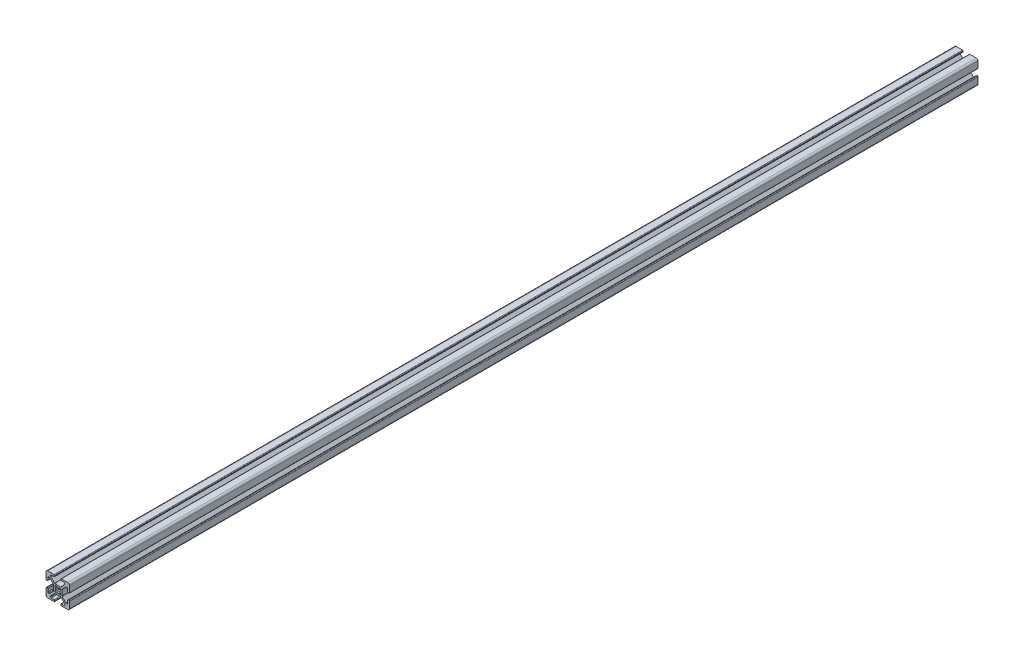
from build123d import *

# Parameters (mm, degrees)
BOSS_EXTRUDE1_DEPTH = 773.68


with BuildPart() as part:
    # Sketch1 → Boss-Extrude1 (new body)
    with BuildSketch(Plane(origin=(0, 0, -25), x_dir=(-1, 0, 0), z_dir=(0, 0, -1))):
        with BuildLine():
            Line((10, -8.5), (10, -3.138))
            ThreePointArc((10, -3.138), (9.851210245, -2.778789755), (9.492, -2.63))
            Line((9.492, -2.63), (9.008, -2.63))
            ThreePointArc((9.008, -2.63), (8.648789755, -2.778789755), (8.5, -3.138))
            Line((8.5, -3.138), (8.5, -5.487))
            ThreePointArc((8.5, -5.487), (8.351210245, -5.846210245), (7.992, -5.995))
            Line((7.992, -5.995), (7.26592049, -5.995))
            ThreePointArc((7.26592049, -5.995), (7.071517306, -5.956330803), (6.906710245, -5.846210245))
            Line((6.906710245, -5.846210245), (3.803789755, -2.743289755))
            ThreePointArc((3.803789755, -2.743289755), (3.693669197, -2.578482694), (3.655, -2.38407951))
            Line((3.655, -2.38407951), (3.655, 2.383759167))
            ThreePointArc((3.655, 2.383759167), (3.693669197, 2.57816235), (3.803789755, 2.742969412))
            Line((3.803789755, 2.742969412), (6.907030588, 5.846210245))
            ThreePointArc((6.907030588, 5.846210245), (7.07183765, 5.956330803), (7.266240833, 5.995))
            Line((7.266240833, 5.995), (7.992, 5.995))
            ThreePointArc((7.992, 5.995), (8.351210245, 5.846210245), (8.5, 5.487))
            Line((8.5, 5.487), (8.5, 3.138))
            ThreePointArc((8.5, 3.138), (8.648789755, 2.778789755), (9.008, 2.63))
            Line((9.008, 2.63), (9.492, 2.63))
            ThreePointArc((9.492, 2.63), (9.851210245, 2.778789755), (10, 3.138))
            Line((10, 3.138), (10, 8.5))
            ThreePointArc((10, 8.5), (9.560660172, 9.560660172), (8.5, 10))
            Line((8.5, 10), (3.138, 10))
            ThreePointArc((3.138, 10), (2.778789755, 9.851210245), (2.63, 9.492))
            Line((2.63, 9.492), (2.63, 9.008))
            ThreePointArc((2.63, 9.008), (2.778789755, 8.648789755), (3.138, 8.5))
            Line((3.138, 8.5), (5.487, 8.5))
            ThreePointArc((5.487, 8.5), (5.846210245, 8.351210245), (5.995, 7.992))
            Line((5.995, 7.992), (5.995, 7.26592049))
            ThreePointArc((5.995, 7.26592049), (5.956330803, 7.071517306), (5.846210245, 6.906710245))
            Line((5.846210245, 6.906710245), (2.743289755, 3.803789755))
            ThreePointArc((2.743289755, 3.803789755), (2.578482694, 3.693669197), (2.38407951, 3.655))
            Line((2.38407951, 3.655), (-2.383759167, 3.655))
            ThreePointArc((-2.383759167, 3.655), (-2.57816235, 3.693669197), (-2.742969412, 3.803789755))
            Line((-2.742969412, 3.803789755), (-5.846210245, 6.907030588))
            ThreePointArc((-5.846210245, 6.907030588), (-5.956330803, 7.07183765), (-5.995, 7.266240833))
            Line((-5.995, 7.266240833), (-5.995, 7.992))
            ThreePointArc((-5.995, 7.992), (-5.846210245, 8.351210245), (-5.487, 8.5))
            Line((-5.487, 8.5), (-3.138, 8.5))
            ThreePointArc((-3.138, 8.5), (-2.778789755, 8.648789755), (-2.63, 9.008))
            Line((-2.63, 9.008), (-2.63, 9.492))
            ThreePointArc((-2.63, 9.492), (-2.778789755, 9.851210245), (-3.138, 10))
            Line((-3.138, 10), (-8.5, 10))
            ThreePointArc((-8.5, 10), (-9.560660172, 9.560660172), (-10, 8.5))
            Line((-10, 8.5), (-10, 3.138))
            ThreePointArc((-10, 3.138), (-9.851210245, 2.778789755), (-9.492, 2.63))
            Line((-9.492, 2.63), (-9.008, 2.63))
            ThreePointArc((-9.008, 2.63), (-8.648789755, 2.778789755), (-8.5, 3.138))
            Line((-8.5, 3.138), (-8.5, 5.487))
            ThreePointArc((-8.5, 5.487), (-8.351210245, 5.846210245), (-7.992, 5.995))
            Line((-7.992, 5.995), (-7.26592049, 5.995))
            ThreePointArc((-7.26592049, 5.995), (-7.071517306, 5.956330803), (-6.906710245, 5.846210245))
            Line((-6.906710245, 5.846210245), (-3.803789755, 2.743289755))
            ThreePointArc((-3.803789755, 2.743289755), (-3.693669197, 2.578482694), (-3.655, 2.38407951))
            Line((-3.655, 2.38407951), (-3.655, -2.383759167))
            ThreePointArc((-3.655, -2.383759167), (-3.693669197, -2.57816235), (-3.803789755, -2.742969412))
            Line((-3.803789755, -2.742969412), (-6.907030588, -5.846210245))
            ThreePointArc((-6.907030588, -5.846210245), (-7.07183765, -5.956330803), (-7.266240833, -5.995))
            Line((-7.266240833, -5.995), (-7.992, -5.995))
            ThreePointArc((-7.992, -5.995), (-8.351210245, -5.846210245), (-8.5, -5.487))
            Line((-8.5, -5.487), (-8.5, -3.138))
            ThreePointArc((-8.5, -3.138), (-8.648789755, -2.778789755), (-9.008, -2.63))
            Line((-9.008, -2.63), (-9.492, -2.63))
            ThreePointArc((-9.492, -2.63), (-9.851210245, -2.778789755), (-10, -3.138))
            Line((-10, -3.138), (-10, -8.5))
            ThreePointArc((-10, -8.5), (-9.560660172, -9.560660172), (-8.5, -10))
            Line((-8.5, -10), (-3.138, -10))
            ThreePointArc((-3.138, -10), (-2.778789755, -9.851210245), (-2.63, -9.492))
            Line((-2.63, -9.492), (-2.63, -9.008))
            ThreePointArc((-2.63, -9.008), (-2.778789755, -8.648789755), (-3.138, -8.5))
            Line((-3.138, -8.5), (-5.487, -8.5))
            ThreePointArc((-5.487, -8.5), (-5.846210245, -8.351210245), (-5.995, -7.992))
            Line((-5.995, -7.992), (-5.995, -7.26592049))
            ThreePointArc((-5.995, -7.26592049), (-5.956330803, -7.071517306), (-5.846210245, -6.906710245))
            Line((-5.846210245, -6.906710245), (-2.743289755, -3.803789755))
            ThreePointArc((-2.743289755, -3.803789755), (-2.578482694, -3.693669197), (-2.38407951, -3.655))
            Line((-2.38407951, -3.655), (2.383759167, -3.655))
            ThreePointArc((2.383759167, -3.655), (2.57816235, -3.693669197), (2.742969412, -3.803789755))
            Line((2.742969412, -3.803789755), (5.846210245, -6.907030588))
            ThreePointArc((5.846210245, -6.907030588), (5.956330803, -7.07183765), (5.995, -7.266240833))
            Line((5.995, -7.266240833), (5.995, -7.992))
            ThreePointArc((5.995, -7.992), (5.846210245, -8.351210245), (5.487, -8.5))
            Line((5.487, -8.5), (3.138, -8.5))
            ThreePointArc((3.138, -8.5), (2.778789755, -8.648789755), (2.63, -9.008))
            Line((2.63, -9.008), (2.63, -9.492))
            ThreePointArc((2.63, -9.492), (2.778789755, -9.851210245), (3.138, -10))
            Line((3.138, -10), (8.5, -10))
            ThreePointArc((8.5, -10), (9.560660172, -9.560660172), (10, -8.5))
        make_face()
        with BuildLine():
            Line((2.304493037, -2.124493037), (2.124493037, -2.304493037))
            ThreePointArc((2.124493037, -2.304493037), (1.35638567, -2.506016078), (0.803729988, -1.935777391))
            ThreePointArc((0.803729988, -1.935777391), (0, -2.096), (-0.803729988, -1.935777391))
            ThreePointArc((-0.803729988, -1.935777391), (-1.35638567, -2.506016078), (-2.124493037, -2.304493037))
            Line((-2.124493037, -2.304493037), (-2.304493037, -2.124493037))
            ThreePointArc((-2.304493037, -2.124493037), (-2.506016078, -1.35638567), (-1.935777391, -0.803729988))
            ThreePointArc((-1.935777391, -0.803729988), (-2.096, 0), (-1.935777391, 0.803729988))
            ThreePointArc((-1.935777391, 0.803729988), (-2.506016078, 1.35638567), (-2.304493037, 2.124493037))
            Line((-2.304493037, 2.124493037), (-2.124493037, 2.304493037))
            ThreePointArc((-2.124493037, 2.304493037), (-1.35638567, 2.506016078), (-0.803729988, 1.935777391))
            ThreePointArc((-0.803729988, 1.935777391), (0, 2.096), (0.803729988, 1.935777391))
            ThreePointArc((0.803729988, 1.935777391), (1.35638567, 2.506016078), (2.124493037, 2.304493037))
            Line((2.124493037, 2.304493037), (2.304493037, 2.124493037))
            ThreePointArc((2.304493037, 2.124493037), (2.506016078, 1.35638567), (1.935777391, 0.803729988))
            ThreePointArc((1.935777391, 0.803729988), (2.096, 0), (1.935777391, -0.803729988))
            ThreePointArc((1.935777391, -0.803729988), (2.506016078, -1.35638567), (2.304493037, -2.124493037))
        make_face(mode=Mode.SUBTRACT)
    extrude(amount=-BOSS_EXTRUDE1_DEPTH)


solid = part.part
